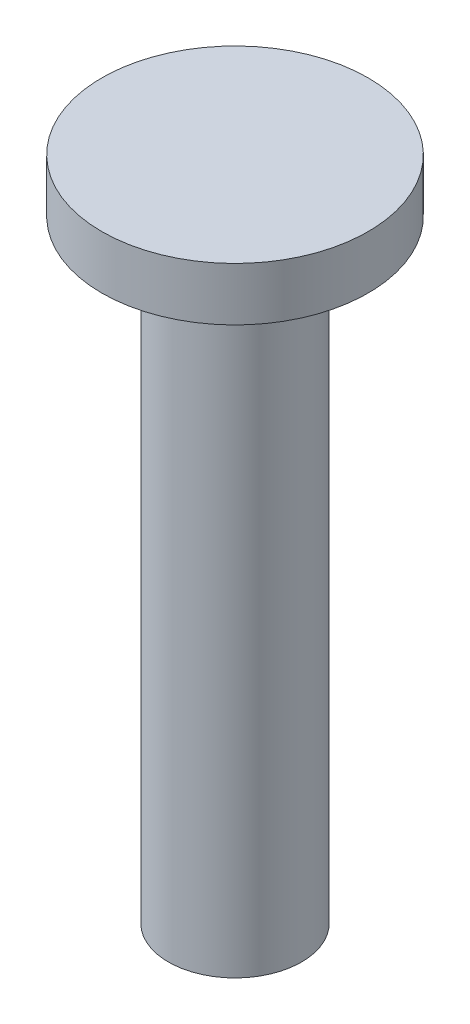
from build123d import *


with BuildPart() as part:
    # 草图1 → 旋转1 (revolve)
    with BuildSketch(Plane.XY):
        Polygon((0, 0), (-1, 0), (-1, 9.2), (-2, 9.2), (-2, 10), (0, 10), align=None)
    revolve(axis=Axis((0, 0, 0), (0, 1, 0)))


solid = part.part
